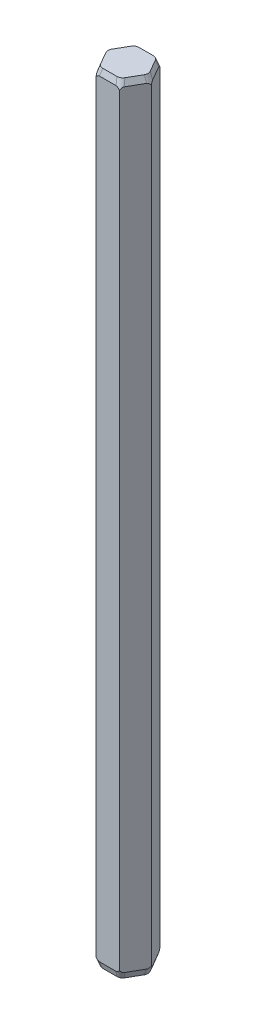
from build123d import *

# Parameters (mm, degrees)
BOSS_EXTRUDE1_DEPTH   = 50
CHAMFER1_SIZE         = 0.4
CHAMFER1_SIZE2        = 0.137731045
CHAMFER1_PART_2_SIZE  = 0.4
CHAMFER1_PART_2_SIZE2 = 0.137731045
CHAMFER1_PART_3_SIZE  = 0.4
CHAMFER1_PART_3_SIZE2 = 0.137731045
CHAMFER1_PART_4_SIZE  = 0.4
CHAMFER1_PART_4_SIZE2 = 0.137731045
CHAMFER1_PART_5_SIZE  = 0.4
CHAMFER1_PART_5_SIZE2 = 0.137731045
CHAMFER1_PART_6_SIZE  = 0.4
CHAMFER1_PART_6_SIZE2 = 0.137731045
FILLET1_R             = 0.4


with BuildPart() as part:
    # Sketch1 → Boss-Extrude1 (new body)
    with BuildSketch(Plane(origin=(0, 0, 0), x_dir=(1, 0, 0), z_dir=(0, 1, 0))):
        Polygon((1.5, 0), (0.75, 1.299038106), (-0.75, 1.299038106), (-1.5, 0), (-0.75, -1.299038106), (0.75, -1.299038106), align=None)
    extrude(amount=BOSS_EXTRUDE1_DEPTH)

    # Chamfer1
    chamfer1_edges = [part.edges().sort_by_distance(p)[0] for p in [
        (0, 50, -1.299038106),
        (0, 0, -1.299038106),
    ]]
    chamfer1_side = [part.faces().sort_by_distance(p)[0] for p in [
        (0, 25, -1.299038106),
    ]]
    chamfer(chamfer1_edges, length=CHAMFER1_SIZE, length2=CHAMFER1_SIZE2, reference=chamfer1_side[0])

    # Chamfer1 part 2
    chamfer1_part_2_edges = [part.edges().sort_by_distance(p)[0] for p in [
        (-1.125, 50, -0.649519053),
        (-1.125, 0, -0.649519053),
    ]]
    chamfer1_part_2_side = [part.faces().sort_by_distance(p)[0] for p in [
        (-1.125, 25, -0.649519053),
    ]]
    chamfer(chamfer1_part_2_edges, length=CHAMFER1_PART_2_SIZE, length2=CHAMFER1_PART_2_SIZE2, reference=chamfer1_part_2_side[0])

    # Chamfer1 part 3
    chamfer1_part_3_edges = [part.edges().sort_by_distance(p)[0] for p in [
        (-1.125, 50, 0.649519053),
        (-1.125, 0, 0.649519053),
    ]]
    chamfer1_part_3_side = [part.faces().sort_by_distance(p)[0] for p in [
        (-1.125, 25, 0.649519053),
    ]]
    chamfer(chamfer1_part_3_edges, length=CHAMFER1_PART_3_SIZE, length2=CHAMFER1_PART_3_SIZE2, reference=chamfer1_part_3_side[0])

    # Chamfer1 part 4
    chamfer1_part_4_edges = [part.edges().sort_by_distance(p)[0] for p in [
        (0, 50, 1.299038106),
        (0, 0, 1.299038106),
    ]]
    chamfer1_part_4_side = [part.faces().sort_by_distance(p)[0] for p in [
        (0, 25, 1.299038106),
    ]]
    chamfer(chamfer1_part_4_edges, length=CHAMFER1_PART_4_SIZE, length2=CHAMFER1_PART_4_SIZE2, reference=chamfer1_part_4_side[0])

    # Chamfer1 part 5
    chamfer1_part_5_edges = [part.edges().sort_by_distance(p)[0] for p in [
        (1.125, 50, 0.649519053),
        (1.125, 0, 0.649519053),
    ]]
    chamfer1_part_5_side = [part.faces().sort_by_distance(p)[0] for p in [
        (1.125, 25, 0.649519053),
    ]]
    chamfer(chamfer1_part_5_edges, length=CHAMFER1_PART_5_SIZE, length2=CHAMFER1_PART_5_SIZE2, reference=chamfer1_part_5_side[0])

    # Chamfer1 part 6
    chamfer1_part_6_edges = [part.edges().sort_by_distance(p)[0] for p in [
        (1.125, 50, -0.649519053),
        (1.125, 0, -0.649519053),
    ]]
    chamfer1_part_6_side = [part.faces().sort_by_distance(p)[0] for p in [
        (1.125, 25, -0.649519053),
    ]]
    chamfer(chamfer1_part_6_edges, length=CHAMFER1_PART_6_SIZE, length2=CHAMFER1_PART_6_SIZE2, reference=chamfer1_part_6_side[0])

    # Fillet1
    fillet1_edges = [part.edges().sort_by_distance(p)[0] for p in [
        (-0.710240472, 0.2, 1.230172583),
        (-1.420480944, 0.2, 0),
        (0.710240472, 0.2, 1.230172583),
        (-0.710240472, 0.2, -1.230172583),
        (1.420480944, 0.2, 0),
        (0.710240472, 0.2, -1.230172583),
        (-0.710240472, 49.8, -1.230172583),
        (0.710240472, 49.8, -1.230172583),
        (-1.420480944, 49.8, 0),
        (1.420480944, 49.8, 0),
        (-0.710240472, 49.8, 1.230172583),
        (0.710240472, 49.8, 1.230172583),
    ]]
    fillet(fillet1_edges, radius=FILLET1_R)


solid = part.part
